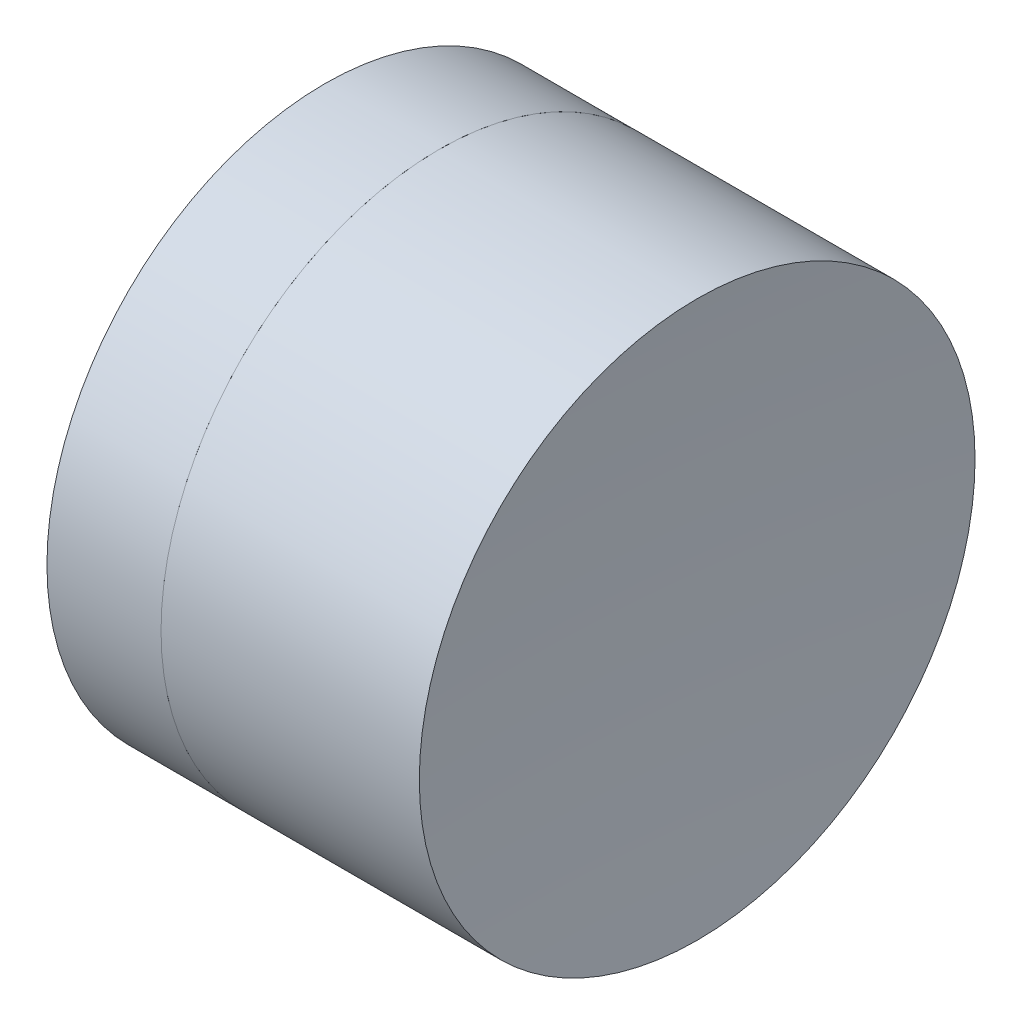
from build123d import *


with BuildPart() as part:
    # 草图1 one side → 旋转1 (revolve)
    with BuildSketch(Plane(origin=(0, 0, 0), x_dir=(1, 0, 0), z_dir=(0, 1, 0)), mode=Mode.PRIVATE) as revolve_1_sk:
        with BuildLine():
            ThreePointArc((1.332768039, 2.5), (0.784043121, 1.303149455), (0.596022485, 0))
            Line((0.596022485, 0), (3.096022485, 0))
            ThreePointArc((3.096022485, 0), (2.908001849, 1.303149455), (2.35927693, 2.5))
            Line((2.35927693, 2.5), (1.332768039, 2.5))
        make_face()
    revolve(revolve_1_sk.sketch.rotate(Axis((-0.816062176, 0, 0), (1, 0, 0)), 180), axis=Axis((-0.816062176, 0, 0), (1, 0, 0)))  # turned: the seam where the file's is


with BuildPart() as body_2:
    # 草图2 one side → 旋转2 (revolve)
    with BuildSketch(Plane(origin=(0, 0, 0), x_dir=(1, 0, 0), z_dir=(0, 1, 0))):
        with BuildLine():
            Line((4.683054119, 2.5), (2.35927693, 2.5))
            ThreePointArc((2.35927693, 2.5), (2.908001849, 1.303149455), (3.096022485, 0))
            Line((3.096022485, 0), (4.596022485, 0))
            ThreePointArc((4.596022485, 0), (4.617786982, 1.250757221), (4.683054119, 2.5))
        make_face()
    revolve(axis=Axis((-0.551919993, 0, 0), (1, 0, 0)))


solid = Compound([part.part, body_2.part])
